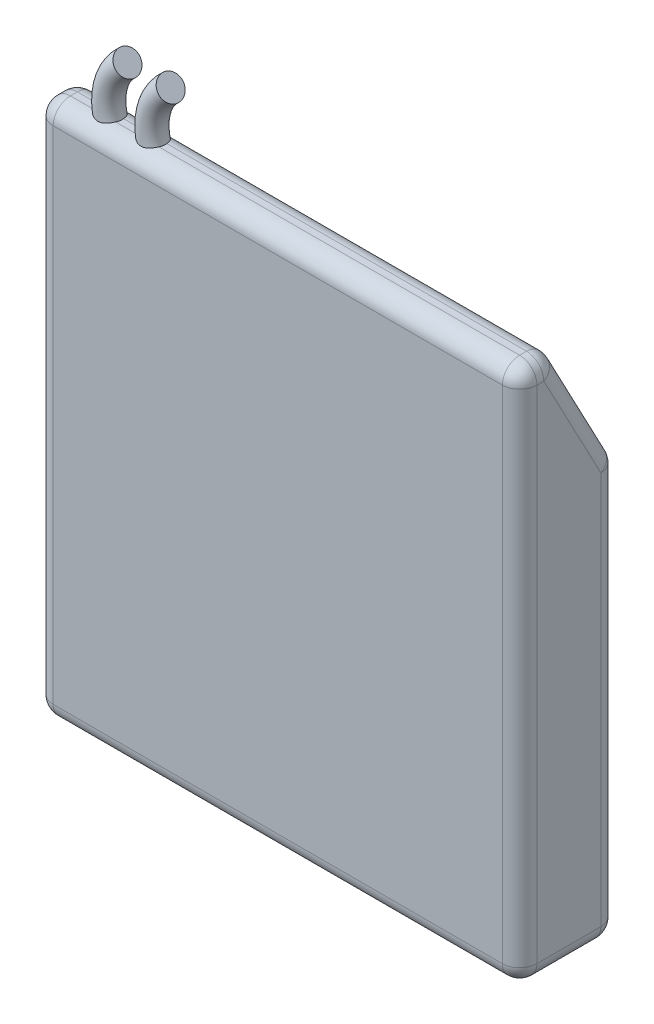
from build123d import *

# Parameters (mm, degrees)
EXTRUDE_1_DEPTH        = 28
FILLET_1_R             = 1
SWEEP_1_PROFILE_R      = 0.7
PATTERN_LINEAR_1_COUNT = 2
PATTERN_LINEAR_1_PITCH = 2.5


with BuildPart() as part:
    # 草图1 → 凸台-拉伸1 (new body)
    with BuildSketch(Plane(origin=(0, 0, 0), x_dir=(0, 0, -1), z_dir=(1, 0, 0))):
        Polygon((0, 0), (0, 31), (2, 31), (5.7, 24), (5.7, 0), align=None)
    extrude(amount=EXTRUDE_1_DEPTH)

    # 圆角1
    fillet_1_edges = [part.edges().sort_by_distance(p)[0] for p in [
        (28, 27.5, -3.85),
        (28, 31, -1),
        (28, 15.5, 0),
        (28, 0, -2.85),
        (0, 15.5, 0),
        (0, 31, -1),
        (0, 27.5, -3.85),
        (0, 12, -5.7),
        (0, 0, -2.85),
        (28, 12, -5.7),
        (14, 0, 0),
        (14, 31, 0),
        (14, 31, -2),
        (14, 24, -5.7),
        (14, 0, -5.7),
    ]]
    fillet(fillet_1_edges, radius=FILLET_1_R)

    # 扫描1: sweep along a path in 草图2
    with BuildLine(Plane.XY.offset(-1.3)) as sweep_1_path:
        ThreePointArc((4.001651966, 34.019317003), (2.935743371, 31.239649146), (4.579965561, 28.757865933))
    # 扫描1 profile (on start of the path) → 扫描1 (sweep)
    with BuildSketch(Plane(origin=(4.001651966, 34.019317003, -1.3), x_dir=(0.6661061501000685, -0.745856954649392, 0), z_dir=(-0.745856954649392, -0.6661061501000685, 0))):
        Circle(SWEEP_1_PROFILE_R)
    sweep_1 = sweep(path=sweep_1_path.line)

    # 阵列(线性)1: 扫描1 ×2
    with Locations(*[(i * PATTERN_LINEAR_1_PITCH, 0, 0) for i in range(1, PATTERN_LINEAR_1_COUNT)]):
        add(sweep_1)


solid = part.part
